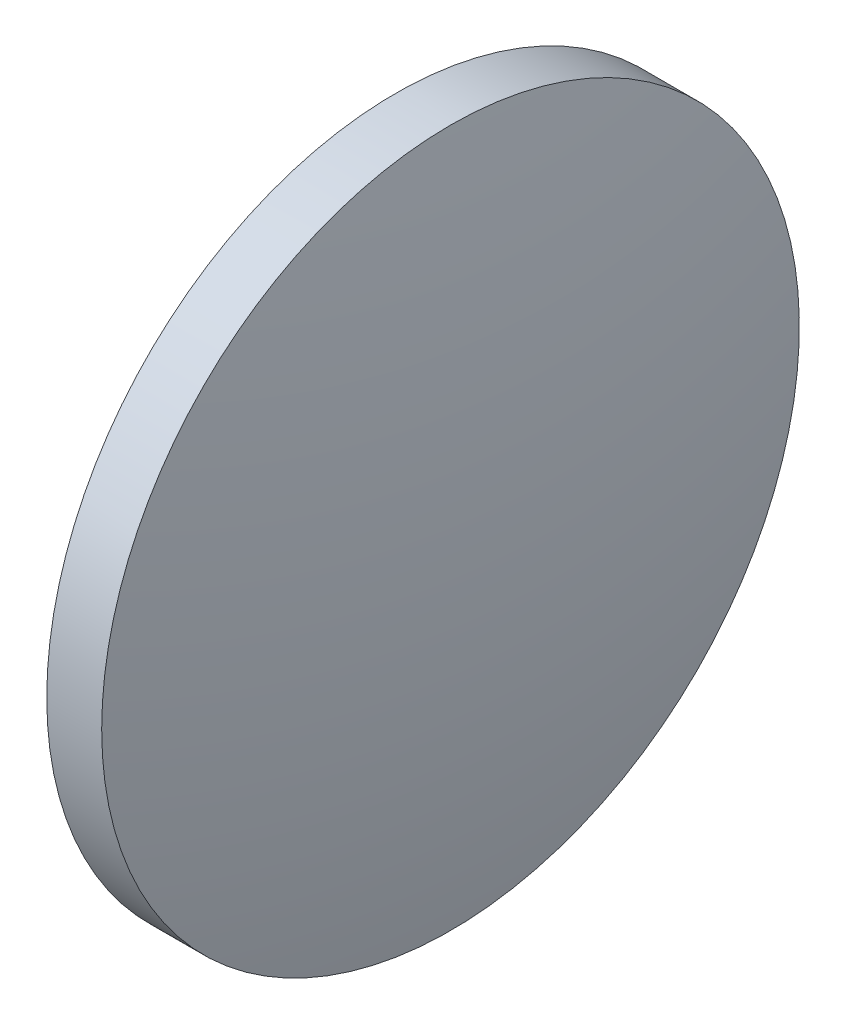
from build123d import *


with BuildPart() as part:
    # 草图1 → 旋转1 (revolve)
    with BuildSketch(Plane.XY):
        with BuildLine():
            Line((389.868049149, 40.44166343), (389.868049149, 53.14166343))
            Line((389.868049149, 53.14166343), (391.868049149, 53.14166343))
            ThreePointArc((391.868049149, 53.14166343), (392.842202241, 46.824844455), (393.168049149, 40.44166343))
            Line((393.168049149, 40.44166343), (389.868049149, 40.44166343))
        make_face()
    revolve(axis=Axis((384.238153098, 40.44166343, 0), (1, 0, 0)))


solid = part.part
